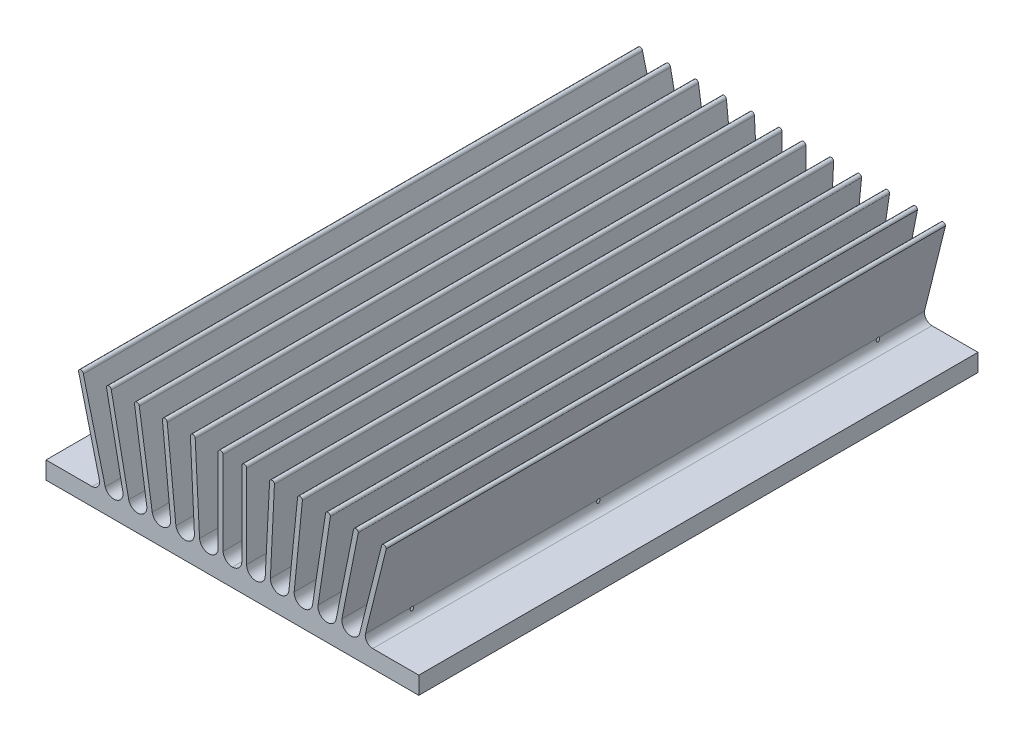
from build123d import *

# Parameters (mm, degrees)
BASE_EXTRUDE_DEPTH        = 152.4
LPATTERN10_COUNT          = 2
LPATTERN10_PITCH          = 60.96
LPATTERN10_COUNT_DIR2     = 2
LPATTERN10_PITCH_DIR2     = 114.3
F_6_32_TAPPED_HOLE1_D     = 2.7051
F_6_32_TAPPED_HOLE1_DEPTH = 7.9502
F_6_32_TAPPED_HOLE1_TIP   = 0.81269403
F_4_40_TAPPED_HOLE2_D     = 2.2606
F_4_40_TAPPED_HOLE2_DEPTH = 7.9502
F_4_40_TAPPED_HOLE2_TIP   = 0.679152758
F_4_40_TAPPED_HOLE5_D     = 2.2606
F_4_40_TAPPED_HOLE5_DEPTH = 7.9502
F_4_40_TAPPED_HOLE5_TIP   = 0.679152758


with BuildPart() as part:
    # Sketch1 → Base-Extrude (new body)
    with BuildSketch(Plane.XY):
        with BuildLine():
            Line((-50.8, 0), (0, 0))
            Line((0, 0), (0, 4.879550307))
            ThreePointArc((0, 4.879550307), (-1.751644367, 5.600016205), (-2.5527, 7.316302594))
            Line((-2.5527, 7.316302594), (-2.5527, 30.150820194))
            ThreePointArc((-2.5527, 30.150820194), (-3.2131, 30.811220194), (-3.8735, 30.150820194))
            Line((-3.8735, 30.150820194), (-3.8735, 7.425352432))
            ThreePointArc((-3.8735, 7.425352432), (-6.284598584, 4.831615738), (-8.949629339, 7.163670088))
            Line((-8.949629339, 7.163670088), (-10.1346, 30.1498))
            ThreePointArc((-10.1346, 30.1498), (-10.795, 30.8102), (-11.4554, 30.1498))
            Line((-11.4554, 30.1498), (-10.349520297, 7.37095828))
            ThreePointArc((-10.349520297, 7.37095828), (-12.662006809, 4.837299559), (-15.393624428, 6.912217766))
            Line((-15.393624428, 6.912217766), (-17.7546, 30.1498))
            ThreePointArc((-17.7546, 30.1498), (-18.415, 30.8102), (-19.0754, 30.1498))
            Line((-19.0754, 30.1498), (-16.836831715, 7.445945007))
            ThreePointArc((-16.836831715, 7.445945007), (-19.07493452, 4.799366554), (-21.845918419, 6.881464032))
            Line((-21.845918419, 6.881464032), (-25.3746, 30.1498))
            ThreePointArc((-25.3746, 30.1498), (-26.035, 30.8102), (-26.6954, 30.1498))
            Line((-26.6954, 30.1498), (-23.348315556, 7.633050107))
            ThreePointArc((-23.348315556, 7.633050107), (-25.325857338, 4.783460588), (-28.253377757, 6.643690714))
            Line((-28.253377757, 6.643690714), (-32.9946, 30.1498))
            ThreePointArc((-32.9946, 30.1498), (-33.655, 30.8102), (-34.3154, 30.1498))
            Line((-34.3154, 30.1498), (-29.829474712, 7.573279283))
            ThreePointArc((-29.829474712, 7.573279283), (-31.751965346, 4.831827803), (-34.659033867, 6.493296752))
            Line((-34.659033867, 6.493296752), (-40.6146, 30.1498))
            ThreePointArc((-40.6146, 30.1498), (-41.275, 30.8102), (-41.9354, 30.1498))
            Line((-41.9354, 30.1498), (-36.240830367, 7.256942601))
            ThreePointArc((-36.240830367, 7.256942601), (-36.660221709, 5.555263105), (-38.229649554, 4.7752))
            Line((-38.229649554, 4.7752), (-50.8, 4.7752))
            Line((-50.8, 4.7752), (-50.8, 0))
        make_face()
    base_extrude = extrude(amount=-BASE_EXTRUDE_DEPTH)

    # Mirror1: Base-Extrude across plane
    add(base_extrude.mirror(Plane(origin=(0, 0, 0), x_dir=(0, 0, 1), z_dir=(1, 0, 0))))

    # Sketch6 → #4-40 Tapped Hole1 (revolve, cut)
    with BuildSketch(Plane(origin=(-30.48, 0, -133.35), x_dir=(0, 0, -1), z_dir=(1, 0, 0))):
        Polygon((0, 0), (0, 8.629352758), (1.1303, 7.9502), (1.1303, 0), align=None)
    f_4_40_tapped_hole1 = revolve(axis=Axis((-30.48, -6.35, -133.35), (0, 1, 0)), mode=Mode.SUBTRACT)

    # LPattern10: 4-40 Tapped Hole1 2 × 2
    with Locations(*[(i * LPATTERN10_PITCH, 0, j * LPATTERN10_PITCH_DIR2) for i in range(LPATTERN10_COUNT) for j in range(LPATTERN10_COUNT_DIR2) if (i, j) != (0, 0)]):
        add(f_4_40_tapped_hole1, mode=Mode.SUBTRACT)

    # #6-32 Tapped Hole1
    with Locations(Plane(origin=(-34.925, 0, -139.7), x_dir=(0, 0, -1), z_dir=(0, -1, 0))):
        with Locations((0, 0), (0, 69.85), (-76.2, 69.85), (-76.2, 0), (-127, 0), (-127, 69.85)):
            Hole(F_6_32_TAPPED_HOLE1_D / 2, depth=F_6_32_TAPPED_HOLE1_DEPTH)
            with Locations((0, 0, -(F_6_32_TAPPED_HOLE1_DEPTH + F_6_32_TAPPED_HOLE1_TIP / 2))):  # 118° drill point
                Cone(0, F_6_32_TAPPED_HOLE1_D / 2, F_6_32_TAPPED_HOLE1_TIP, mode=Mode.SUBTRACT)

    # #4-40 Tapped Hole2
    with Locations(Plane(origin=(-34.925, 0, -32.385), x_dir=(0, 0, -1), z_dir=(0, -1, 0))):
        with Locations((0, 0), (10.795, 8.255), (76.835, 61.595), (87.63, 69.85)):
            Hole(F_4_40_TAPPED_HOLE2_D / 2, depth=F_4_40_TAPPED_HOLE2_DEPTH)
            with Locations((0, 0, -(F_4_40_TAPPED_HOLE2_DEPTH + F_4_40_TAPPED_HOLE2_TIP / 2))):  # 118° drill point
                Cone(0, F_4_40_TAPPED_HOLE2_D / 2, F_4_40_TAPPED_HOLE2_TIP, mode=Mode.SUBTRACT)

    # #4-40 Tapped Hole5
    with Locations(Plane.XZ):
        with Locations((-34.925, -53.975)):
            Hole(F_4_40_TAPPED_HOLE5_D / 2, depth=F_4_40_TAPPED_HOLE5_DEPTH)
            with Locations((0, 0, -(F_4_40_TAPPED_HOLE5_DEPTH + F_4_40_TAPPED_HOLE5_TIP / 2))):  # 118° drill point
                Cone(0, F_4_40_TAPPED_HOLE5_D / 2, F_4_40_TAPPED_HOLE5_TIP, mode=Mode.SUBTRACT)


solid = part.part
